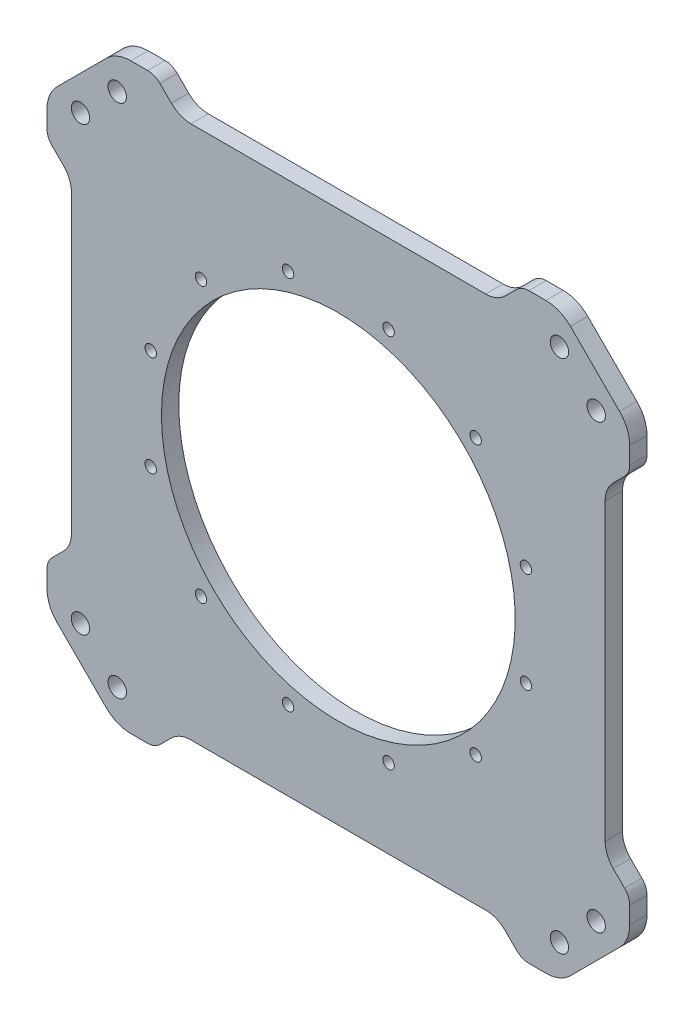
from build123d import *

# Parameters (mm, degrees)
SKETCH_1_W               = 168
SKETCH_1_H               = 168
EXTRUDE_1_DEPTH          = 5
CUT_EXTRUDE_1_DEPTH      = 6
SKETCH_5_R               = 51
CUT_EXTRUDE_4_DEPTH      = 6
SKETCH_6_R               = 1.65
CUT_EXTRUDE_5_DEPTH      = 6
PATTERN_CIRCULAR_2_COUNT = 12
SKETCH_7_R               = 2.65
CUT_EXTRUDE_6_DEPTH      = 6
PATTERN_CIRCULAR_3_COUNT = 4
FILLET_1_R               = 10
CUT_EXTRUDE_7_DEPTH      = 1
CUT_EXTRUDE_7_DEPTH_BACK = 6
FILLET_2_R               = 8
FILLET_3_R               = 5


with BuildPart() as part:
    # 草图1 → 凸台-拉伸1 (new body)
    with BuildSketch(Plane.XY):
        Rectangle(SKETCH_1_W, SKETCH_1_H)
    extrude(amount=EXTRUDE_1_DEPTH)

    # 草图2 → 切除-拉伸1 (cut, through all)
    with BuildSketch(Plane.XY.offset(5)):
        Polygon((64, 84), (84, 64), (84, 84), align=None)
        Polygon((64, -84), (84, -84), (84, -64), align=None)
        Polygon((-84, -64), (-84, -84), (-64, -84), align=None)
        Polygon((-64, 84), (-84, 84), (-84, 64), align=None)
    extrude(amount=-CUT_EXTRUDE_1_DEPTH, mode=Mode.SUBTRACT)

    # 草图5 → 切除-拉伸4 (cut, through all)
    with BuildSketch(Plane(origin=(0, 0, 0), x_dir=(-1, 0, 0), z_dir=(0, 0, -1))):
        Circle(SKETCH_5_R)
    extrude(amount=-CUT_EXTRUDE_4_DEPTH, mode=Mode.SUBTRACT)

    # 草图6 → 切除-拉伸5 (cut, through all)
    with BuildSketch(Plane(origin=(0, 0, 0), x_dir=(-1, 0, 0), z_dir=(0, 0, -1))):
        with Locations((-39.597979746, -39.597979746)):
            Circle(SKETCH_6_R)
    cut_extrude_5 = extrude(amount=-CUT_EXTRUDE_5_DEPTH, mode=Mode.SUBTRACT)

    # 阵列(圆周)2: 切除-拉伸5 ×12 about axis
    pattern_circular_2_axis = Axis((0, 0, 0), (0, 0, 1))
    for i in range(1, PATTERN_CIRCULAR_2_COUNT):
        add(cut_extrude_5.rotate(pattern_circular_2_axis, i * 360 / PATTERN_CIRCULAR_2_COUNT), mode=Mode.SUBTRACT)

    # 草图7 → 切除-拉伸6 (cut, through all)
    with BuildSketch(Plane(origin=(0, 0, 0), x_dir=(-1, 0, 0), z_dir=(0, 0, -1))):
        with Locations((74.353553391, 63.746951673)):
            Circle(SKETCH_7_R)
        with Locations((63.746951673, 74.353553391)):
            Circle(SKETCH_7_R)
    cut_extrude_6 = extrude(amount=-CUT_EXTRUDE_6_DEPTH, mode=Mode.SUBTRACT)

    # 阵列(圆周)3: 切除-拉伸6 ×4 about axis
    pattern_circular_3_axis = Axis((0, 0, 0), (0, 0, 1))
    for i in range(1, PATTERN_CIRCULAR_3_COUNT):
        add(cut_extrude_6.rotate(pattern_circular_3_axis, i * 360 / PATTERN_CIRCULAR_3_COUNT), mode=Mode.SUBTRACT)

    # 圆角1
    fillet_1_edges = [part.edges().sort_by_distance(p)[0] for p in [
        (-64, 84, 2.5),
        (-84, 64, 2.5),
        (-84, -64, 2.5),
        (-64, -84, 2.5),
        (64, -84, 2.5),
        (84, -64, 2.5),
        (64, 84, 2.5),
        (84, 64, 2.5),
    ]]
    fillet(fillet_1_edges, radius=FILLET_1_R)

    # 草图8 → 切除-拉伸7 (cut, two sides)
    with BuildSketch(Plane(origin=(0, 0, 0), x_dir=(-1, 0, 0), z_dir=(0, 0, -1))) as cut_extrude_7_sk:
        Polygon((-84, -52.887301628), (-84, 52.887301628), (-76.928932188, 45.816233816), (-76.928932188, -45.816233816), align=None)
        Polygon((-52.887301628, 84), (52.887301628, 84), (45.816233816, 76.928932188), (-45.816233816, 76.928932188), align=None)
        Polygon((84, 52.887301628), (76.928932188, 45.816233816), (76.928932188, -45.816233816), (84, -52.887301628), align=None)
        Polygon((52.887301628, -84), (-52.887301628, -84), (-45.816233816, -76.928932188), (45.816233816, -76.928932188), align=None)
    extrude(amount=CUT_EXTRUDE_7_DEPTH, mode=Mode.SUBTRACT)
    extrude(cut_extrude_7_sk.sketch, amount=-CUT_EXTRUDE_7_DEPTH_BACK, mode=Mode.SUBTRACT)

    # 圆角2
    fillet_2_edges = [part.edges().sort_by_distance(p)[0] for p in [
        (76.928932188, 45.816233816, 2.5),
        (76.928932188, -45.816233816, 2.5),
        (45.816233816, 76.928932188, 2.5),
        (-45.816233816, 76.928932188, 2.5),
        (-76.928932188, -45.816233816, 2.5),
        (-76.928932188, 45.816233816, 2.5),
        (-45.816233816, -76.928932188, 2.5),
        (45.816233816, -76.928932188, 2.5),
    ]]
    fillet(fillet_2_edges, radius=FILLET_2_R)

    # 圆角3
    fillet_3_edges = [part.edges().sort_by_distance(p)[0] for p in [
        (84, 52.887301628, 2.5),
        (84, -52.887301628, 2.5),
        (52.887301628, 84, 2.5),
        (-52.887301628, 84, 2.5),
        (-84, 52.887301628, 2.5),
        (-84, -52.887301628, 2.5),
        (-52.887301628, -84, 2.5),
        (52.887301628, -84, 2.5),
    ]]
    fillet(fillet_3_edges, radius=FILLET_3_R)


solid = part.part
